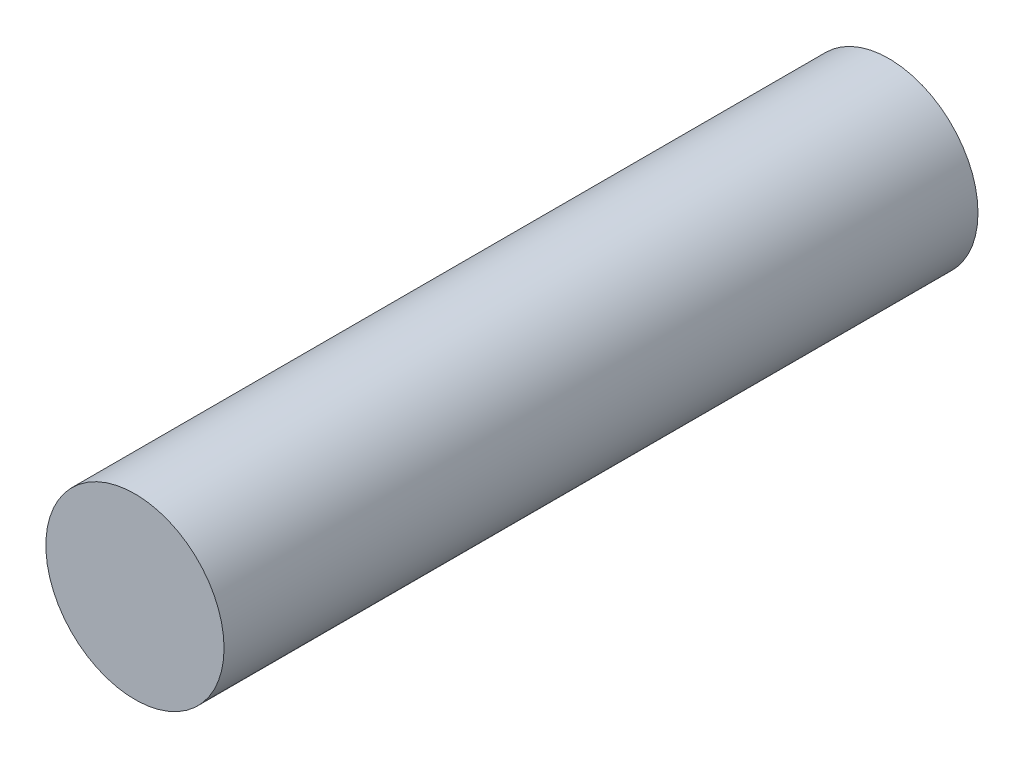
from build123d import *

# Parameters (mm, degrees)
SKETCH_1_R      = 1.3
EXTRUDE_1_DEPTH = 5.5


with BuildPart() as part:
    # Эскиз1 → Бобышка-Вытянуть1 (new body, symmetric)
    with BuildSketch(Plane.XY):
        Circle(SKETCH_1_R)
    extrude(amount=EXTRUDE_1_DEPTH, both=True)


solid = part.part
